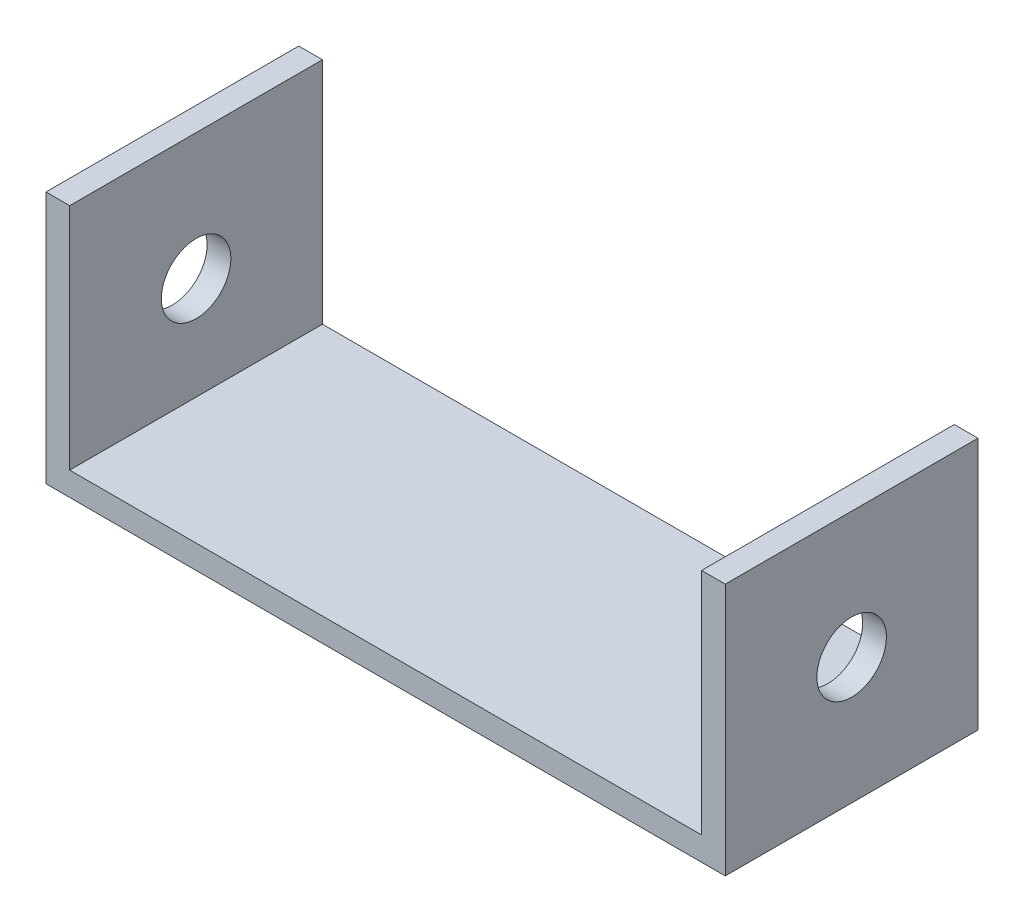
from build123d import *

# Parameters (mm, degrees)
SKETCH1_W           = 127
SKETCH1_H           = 50.8
BOSS_EXTRUDE2_DEPTH = 4.7625
SKETCH3_W           = 4.7625
SKETCH3_H           = 50.8
BOSS_EXTRUDE3_DEPTH = 50.8
SKETCH4_R           = 6.985
CUT_EXTRUDE1_DEPTH  = 137.525


with BuildPart() as part:
    # Sketch1 → Boss-Extrude2 (new body)
    with BuildSketch(Plane(origin=(0, 0, 0), x_dir=(1, 0, 0), z_dir=(0, 1, 0))):
        with Locations((-6.634328358, 6.065671642)):
            Rectangle(SKETCH1_W, SKETCH1_H)
    extrude(amount=BOSS_EXTRUDE2_DEPTH)

    # Sketch3 → Boss-Extrude3 (add)
    with BuildSketch(Plane(origin=(0, 0, 0), x_dir=(1, 0, 0), z_dir=(0, 1, 0))):
        with Locations((59.246921642, 6.065671642)):
            Rectangle(SKETCH3_W, SKETCH3_H)
        with Locations((-72.515578358, 6.065671642)):
            Rectangle(SKETCH3_W, SKETCH3_H)
    extrude(amount=BOSS_EXTRUDE3_DEPTH)

    # Sketch4 → Cut-Extrude1 (cut, through all)
    with BuildSketch(Plane.ZY.offset(74.896828358)):
        with Locations((-6.065671642, 25.4)):
            Circle(SKETCH4_R)
    extrude(amount=-CUT_EXTRUDE1_DEPTH, mode=Mode.SUBTRACT)


solid = part.part
